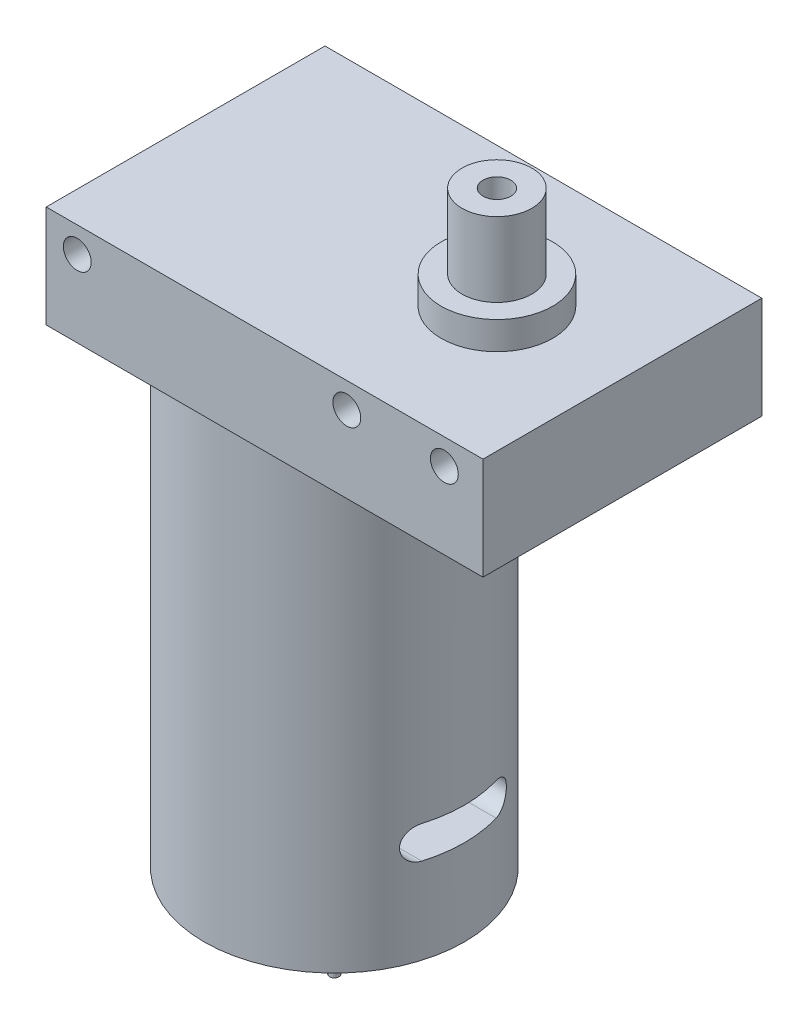
from build123d import *

# Parameters (mm, degrees)
SKETCH_1_W          = 47
SKETCH_1_H          = 30
EXTRUDE_1_DEPTH     = 11
SKETCH_2_R          = 6
EXTRUDE_2_DEPTH     = 3
SKETCH_3_R          = 3.75277675
EXTRUDE_3_DEPTH     = 8
SKETCH_4_R          = 14
EXTRUDE_4_DEPTH     = 50
SKETCH_5_R          = 5
EXTRUDE_5_DEPTH     = 2
SKETCH_6_R          = 1.5
CUT_EXTRUDE_1_DEPTH = 31
CUT_EXTRUDE_2_DEPTH = 48
SKETCH_9_R          = 1.5
CUT_EXTRUDE_3_DEPTH = 8
SKETCH_11_R         = 0.5
EXTRUDE_6_DEPTH     = 8


with BuildPart() as part:
    # 草图1 → 凸台-拉伸1 (new body)
    with BuildSketch(Plane(origin=(0, 0, 0), x_dir=(1, 0, 0), z_dir=(0, 1, 0))):
        with Locations((23.5, -15)):
            Rectangle(SKETCH_1_W, SKETCH_1_H)
    extrude(amount=EXTRUDE_1_DEPTH)

    # 草图2 → 凸台-拉伸2 (add)
    with BuildSketch(Plane(origin=(0, 11, 0), x_dir=(1, 0, 0), z_dir=(0, 1, 0))):
        with Locations((33.5, -15)):
            Circle(SKETCH_2_R)
    extrude(amount=EXTRUDE_2_DEPTH)

    # 草图3 → 凸台-拉伸3 (add)
    with BuildSketch(Plane(origin=(0, 14, 0), x_dir=(1, 0, 0), z_dir=(0, 1, 0))):
        with Locations((33.5, -15)):
            Circle(SKETCH_3_R)
    extrude(amount=EXTRUDE_3_DEPTH)

    # 草图4 → 凸台-拉伸4 (add)
    with BuildSketch(Plane.XZ):
        with Locations((16, 15)):
            Circle(SKETCH_4_R)
    extrude(amount=EXTRUDE_4_DEPTH)

    # 草图5 → 凸台-拉伸5 (add)
    with BuildSketch(Plane.XZ.offset(50)):
        with Locations((16, 15)):
            Circle(SKETCH_5_R)
    extrude(amount=EXTRUDE_5_DEPTH)

    # 草图6 → 切除-拉伸1 (cut, through all)
    with BuildSketch(Plane.XY.offset(30)):
        with Locations((3.340757383, 8.25)):
            Circle(SKETCH_6_R)
        with Locations((32.340757383, 8.25)):
            Circle(SKETCH_6_R)
        with Locations((42.840757383, 8.25)):
            Circle(SKETCH_6_R)
    extrude(amount=-CUT_EXTRUDE_1_DEPTH, mode=Mode.SUBTRACT)

    # 草图7 → 切除-拉伸2 (cut, through all)
    with BuildSketch(Plane.ZY):
        with BuildLine():
            Line((11, -37.25), (19, -37.25))
            ThreePointArc((19, -37.25), (20.75, -39), (19, -40.75))
            Line((19, -40.75), (11, -40.75))
            ThreePointArc((11, -40.75), (9.25, -39), (11, -37.25))
        make_face()
    extrude(amount=-CUT_EXTRUDE_2_DEPTH, mode=Mode.SUBTRACT)

    # 草图9 → 切除-拉伸3 (cut)
    with BuildSketch(Plane(origin=(0, 22, 0), x_dir=(1, 0, 0), z_dir=(0, 1, 0))):
        with Locations((33.5, -15)):
            Circle(SKETCH_9_R)
    extrude(amount=-CUT_EXTRUDE_3_DEPTH, mode=Mode.SUBTRACT)

    # 草图11 → 凸台-拉伸6 (add)
    with BuildSketch(Plane.XZ.offset(52)):
        with Locations((16, 15)):
            Circle(SKETCH_11_R)
    extrude(amount=EXTRUDE_6_DEPTH)


solid = part.part
